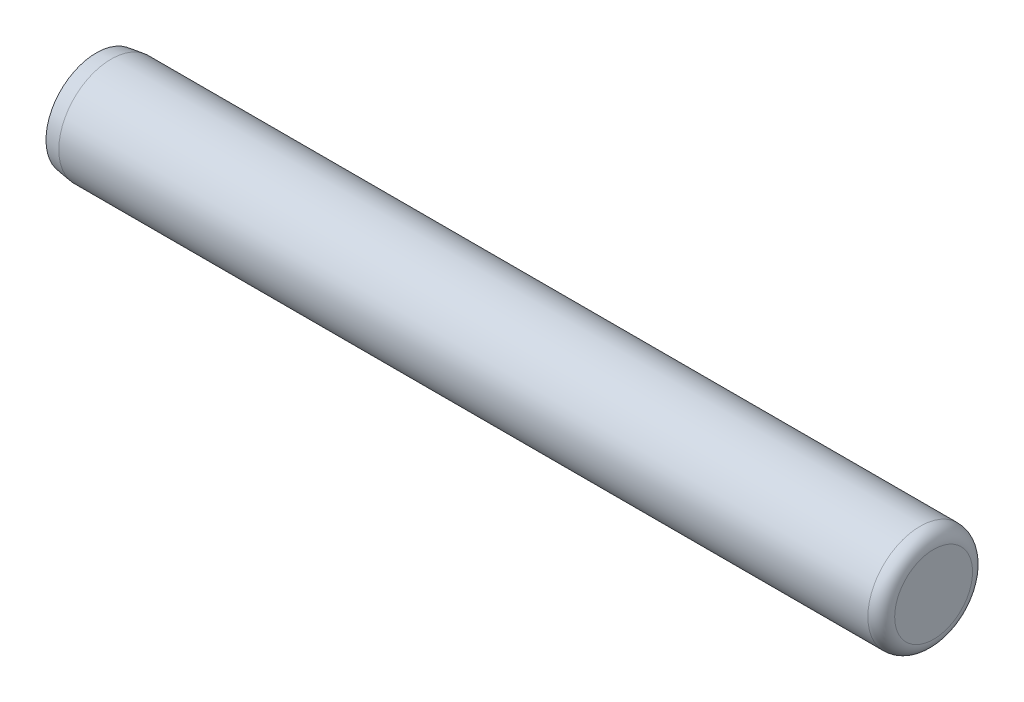
from build123d import *


with BuildPart() as part:
    # Sketch3 → Revolve1 (revolve)
    with BuildSketch(Plane.XY):
        with BuildLine():
            Line((-12.7, 0), (12.7, 0))
            Line((12.7, 0), (12.7, 1.1811))
            ThreePointArc((12.7, 1.1811), (12.580968196, 1.468468196), (12.2936, 1.5875))
            Line((12.2936, 1.5875), (-12.248174023, 1.5875))
            Line((-12.248174023, 1.5875), (-12.7, 1.524))
            Line((-12.7, 1.524), (-12.7, 0))
        make_face()
    revolve(axis=Axis((-12.7, 0, 0), (1, 0, 0)))


solid = part.part
